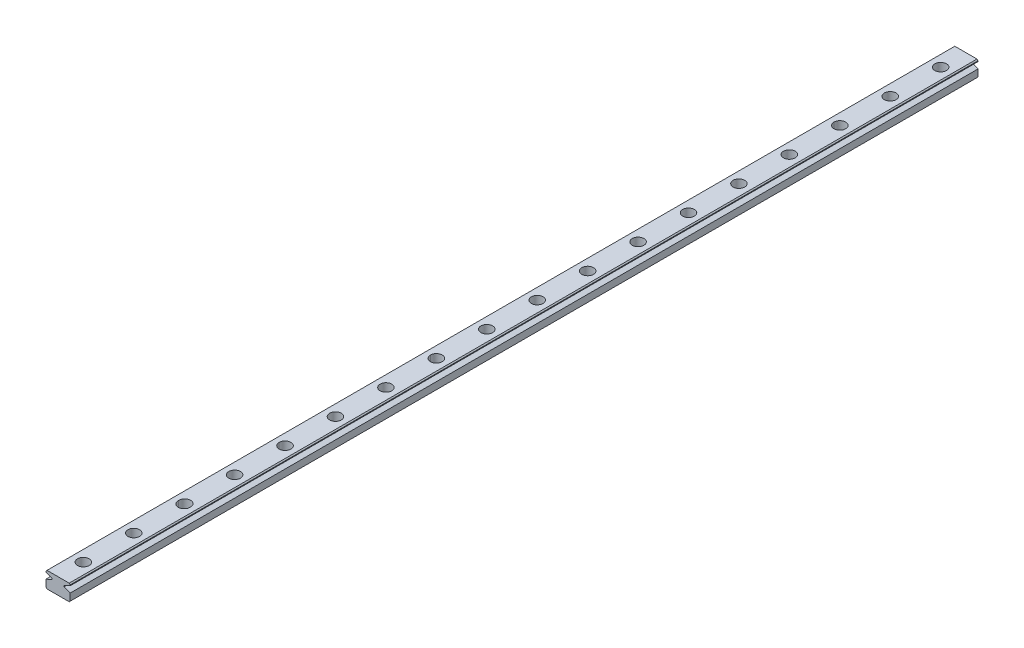
from build123d import *

# Parameters (mm, degrees)
EXTRUDE_1_DEPTH           = 450
HOLE_WIZARD_5_D           = 3.5
HOLE_WIZARD_5_CBORE_D     = 5.8
HOLE_WIZARD_5_CBORE_DEPTH = 4.5
HOLE_WIZARD_4_D           = 3.5
HOLE_WIZARD_4_CBORE_D     = 5.8
HOLE_WIZARD_4_CBORE_DEPTH = 4.5
HOLE_WIZARD_3_D           = 3.5
HOLE_WIZARD_3_DEPTH       = 7.916912277
HOLE_WIZARD_3_CBORE_D     = 5.8
HOLE_WIZARD_3_CBORE_DEPTH = 4.5


with BuildPart() as part:
    # 草图1 → 凸台-拉伸1 (new body)
    with BuildSketch(Plane.XY):
        Polygon((5.617628384, 4.221881307), (16.617628384, 4.221881307), (17.117628384, 4.721881307), (17.117628384, 8.221881307), (14.117628384, 9.445409037), (14.117628384, 9.987809251), (17.117628384, 11.343384147), (17.117628384, 11.721881307), (16.617628384, 12.221881307), (5.617628384, 12.221881307), (5.117628384, 11.721881307), (5.117628384, 11.211336981), (8.117628384, 9.987809251), (8.117628384, 9.445409037), (5.117628384, 8.221881307), (5.117628384, 4.721881307), align=None)
    extrude(amount=EXTRUDE_1_DEPTH)

    # 孔5 (through all)
    with Locations(Plane(origin=(11.117628384, 12.221881307, 12.5), x_dir=(0, 0, 1), z_dir=(0, 1, 0))):
        with Locations((0, 0), (25, 0), (50.00439355, 0), (75, 0), (100, 0), (125, 0), (150, 0), (175, 0), (200, 0), (225, 0), (250, 0), (275, 0), (300, 0), (325, 0), (350, 0), (375, 0), (400, 0), (425, 0)):
            CounterBoreHole(HOLE_WIZARD_5_D / 2, HOLE_WIZARD_5_CBORE_D / 2, HOLE_WIZARD_5_CBORE_DEPTH)

    # 孔4 (through all)
    with Locations(Plane(origin=(11.117628384, 12.221881307, 412.5), x_dir=(0, 0, 1), z_dir=(0, 1, 0))):
        with Locations((0, 0), (-25, 0), (-74.975489716, 0), (-75, 0), (-100, 0), (-150.000497417, 0), (-150, 0), (-175, 0), (-200, 0), (-225, 0), (-250, 0), (-275, 0), (-300, 0), (-325, 0), (-350, 0), (-375, 0)):
            CounterBoreHole(HOLE_WIZARD_4_D / 2, HOLE_WIZARD_4_CBORE_D / 2, HOLE_WIZARD_4_CBORE_DEPTH)

    # 孔3
    with Locations(Plane(origin=(11.117628384, 12.221881307, 387.223861755), x_dir=(0, 0, 1), z_dir=(0, 1, 0))):
        with Locations((0, 0)):
            CounterBoreHole(HOLE_WIZARD_3_D / 2, HOLE_WIZARD_3_CBORE_D / 2, HOLE_WIZARD_3_CBORE_DEPTH, depth=HOLE_WIZARD_3_DEPTH)


solid = part.part
